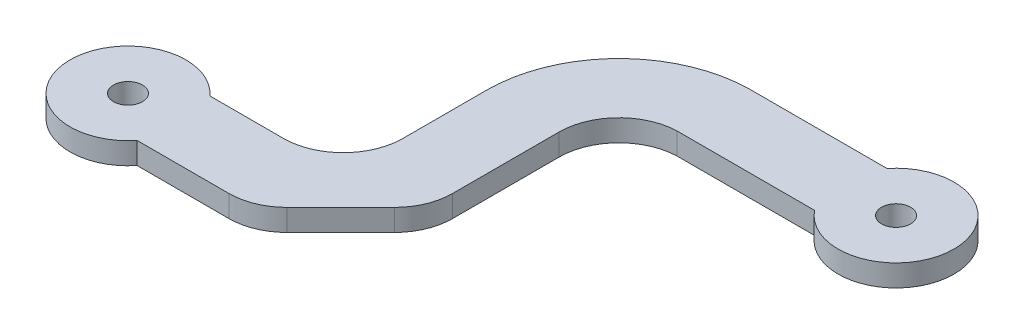
from build123d import *

# Parameters (mm, degrees)
BOSS_EXTRUDE1_DEPTH = 1.5
FILLET1_R           = 4
SKETCH2_R           = 1
CUT_EXTRUDE1_DEPTH  = 11.5


with BuildPart() as part:
    # Sketch1 → Boss-Extrude1 (new body)
    with BuildSketch(Plane(origin=(0, 0, 0), x_dir=(1, 0, 0), z_dir=(0, 1, 0))):
        with BuildLine():
            Line((21.165401421, 16.688429867), (30.665401421, 16.688429867))
            ThreePointArc((30.665401421, 16.688429867), (37.78790042, 19.188429867), (30.665401421, 21.688429867))
            Line((30.665401421, 21.688429867), (21.165401421, 21.688429867))
            ThreePointArc((21.165401421, 21.688429867), (14.799770492, 18.961430624), (12.175333046, 12.552834047))
            Line((12.175333046, 12.552834047), (17.175333046, 12.552834047))
            ThreePointArc((17.175333046, 12.552834047), (18.33546909, 15.426150877), (21.165401421, 16.688429867))
        make_face()
        with BuildLine():
            ThreePointArc((8.055333046, 2.670166466), (10.968612985, 3.876886527), (12.175333046, 6.790166466))
            Line((12.175333046, 6.790166466), (12.175333046, 12.552834047))
            Line((12.175333046, 12.552834047), (17.175333046, 12.552834047))
            Line((17.175333046, 12.552834047), (17.175333046, 3.552834047))
            Line((17.175333046, 3.552834047), (11.122498999, -2.5))
            Line((11.122498999, -2.5), (3.122498999, -2.5))
            ThreePointArc((3.122498999, -2.5), (-3.99844492, -0.111526763), (2.978289953, 2.670166466))
            Line((2.978289953, 2.670166466), (8.055333046, 2.670166466))
        make_face()
    extrude(amount=BOSS_EXTRUDE1_DEPTH)

    # Fillet1
    fillet1_edges = [part.edges().sort_by_distance(p)[0] for p in [
        (17.175333046, 0.75, -3.552834047),
        (11.122498999, 0.75, 2.5),
    ]]
    fillet(fillet1_edges, radius=FILLET1_R)

    # Sketch2 → Cut-Extrude1 (cut)
    with BuildSketch(Plane(origin=(0, 1.5, 0), x_dir=(1, 0, 0), z_dir=(0, 1, 0))):
        Circle(SKETCH2_R)
        with Locations((33.78790042, 19.188429867)):
            Circle(SKETCH2_R)
    extrude(amount=-CUT_EXTRUDE1_DEPTH, mode=Mode.SUBTRACT)


solid = part.part
